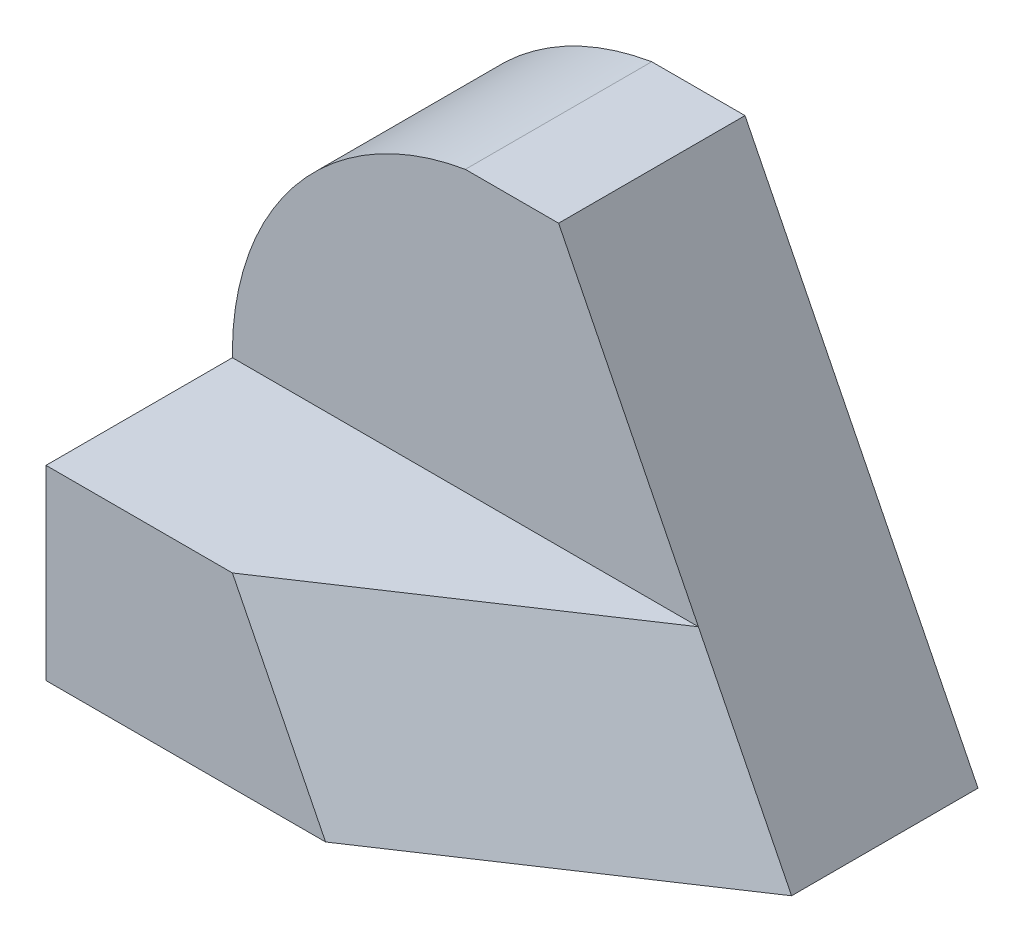
from build123d import *

# Parameters (mm, degrees)
SKETCH1_W           = 6
SKETCH1_H           = 5
BOSS_EXTRUDE1_DEPTH = 2
SKETCH2_W           = 6
SKETCH2_H           = 2
BOSS_EXTRUDE2_DEPTH = 2
CUT_EXTRUDE1_DEPTH  = 10
CUT_EXTRUDE2_DEPTH  = 10
CUT_EXTRUDE3_DEPTH  = 10


with BuildPart() as part:
    # Sketch1 → Boss-Extrude1 (new body)
    with BuildSketch(Plane.XY):
        with Locations((3, 2.5)):
            Rectangle(SKETCH1_W, SKETCH1_H)
    extrude(amount=BOSS_EXTRUDE1_DEPTH)

    # Sketch2 → Boss-Extrude2 (add)
    with BuildSketch(Plane.XY.offset(2)):
        with Locations((3, 1)):
            Rectangle(SKETCH2_W, SKETCH2_H)
    extrude(amount=BOSS_EXTRUDE2_DEPTH)

    # 3DSketch1 → Cut-Extrude1 (cut, along a direction that is not the sketch's normal)
    with BuildSketch(Plane(origin=(6, 0, 2), x_dir=(-0.816496580927726, 0.4082482904638629, 0.40824829046386285), z_dir=(-0.5345224838248487, -0.26726124191242434, -0.8017837257372732))):
        Polygon((0, 0), (3.265986324, -1.527525232), (4.898979486, 0), (1.632993162, 1.527525232), align=None)
    extrude(amount=-CUT_EXTRUDE1_DEPTH, dir=(-1, 0, 0), mode=Mode.SUBTRACT)

    # Sketch3 → Cut-Extrude2 (cut)
    with BuildSketch(Plane.XY.offset(2)):
        Polygon((6, 0), (5, 2), (3.5, 5), (6, 5), align=None)
    extrude(amount=-CUT_EXTRUDE2_DEPTH, mode=Mode.SUBTRACT)

    # Sketch4 → Cut-Extrude3 (cut)
    with BuildSketch(Plane.XY.offset(2)):
        with BuildLine():
            ThreePointArc((0, 2.084019689), (0.721936041, 3.994383965), (2.499411695, 5))
            Line((2.499411695, 5), (0, 5))
            Line((0, 5), (0, 2.084019689))
        make_face()
    extrude(amount=-CUT_EXTRUDE3_DEPTH, mode=Mode.SUBTRACT)


solid = part.part
